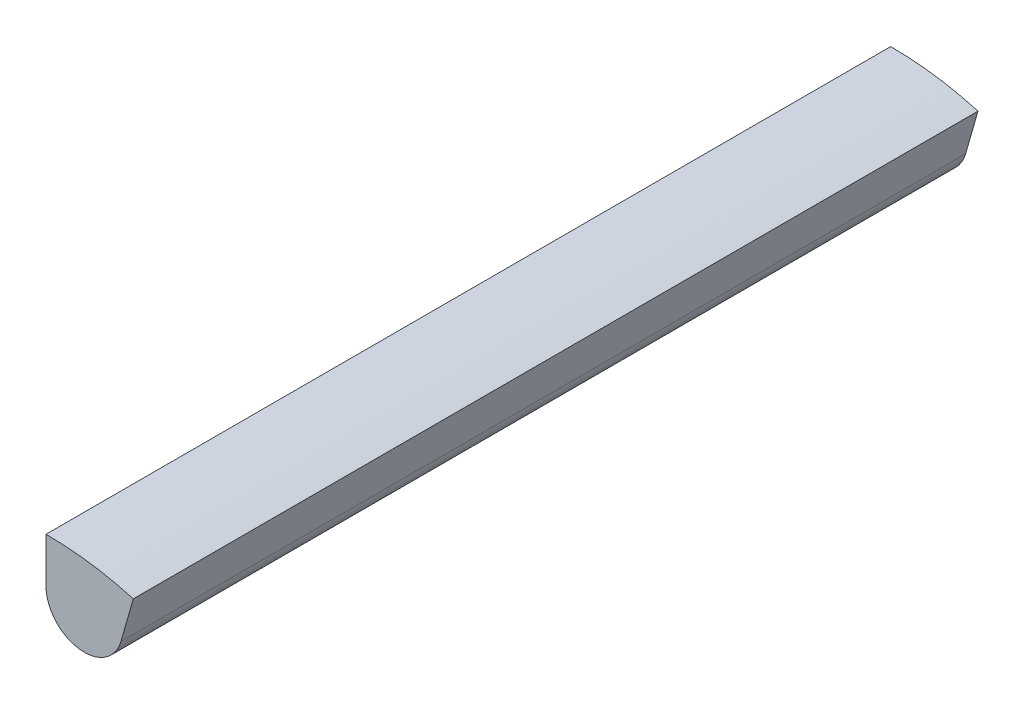
from build123d import *

# Parameters (mm, degrees)
BOSS_EXTRUDE1_DEPTH = 100


with BuildPart() as part:
    # Sketch1 → Boss-Extrude1 (new body)
    with BuildSketch(Plane.XY):
        with BuildLine():
            ThreePointArc((5.152623222, 36.662819266), (1.555688273, 35.597358594), (0, 32.183712234))
            ThreePointArc((0, 32.183712234), (1.109479422, 29.216274726), (3.89362834, 27.704605202))
            Line((3.89362834, 27.704605202), (5.152623222, 36.662819266))
        make_face()
        with BuildLine():
            ThreePointArc((3.89362834, 27.704605202), (6.986596787, 28.390299861), (8.871033436, 30.936970137))
            ThreePointArc((8.871033436, 30.936970137), (9.002232837, 31.554214965), (9.046251562, 32.183712234))
            ThreePointArc((9.046251562, 32.183712234), (7.936772141, 35.151149742), (5.152623222, 36.662819266))
            Line((5.152623222, 36.662819266), (3.89362834, 27.704605202))
        make_face()
        with BuildLine():
            ThreePointArc((9.046251562, 32.183712234), (9.002232837, 31.554214965), (8.871033436, 30.936970137))
            Line((8.871033436, 30.936970137), (10.336400843, 36.047313598))
            ThreePointArc((10.336400843, 36.047313598), (7.796688406, 36.680535028), (5.218991286, 37.135052578))
            Line((5.218991286, 37.135052578), (5.152623222, 36.662819266))
            ThreePointArc((5.152623222, 36.662819266), (7.936772141, 35.151149742), (9.046251562, 32.183712234))
        make_face()
        with BuildLine():
            Line((0, 37.5), (0, 32.183712234))
            ThreePointArc((0, 32.183712234), (1.555688273, 35.597358594), (5.152623222, 36.662819266))
            Line((5.152623222, 36.662819266), (5.218991286, 37.135052578))
            ThreePointArc((5.218991286, 37.135052578), (2.615867765, 37.408651885), (0, 37.5))
        make_face()
    extrude(amount=BOSS_EXTRUDE1_DEPTH)


solid = part.part
